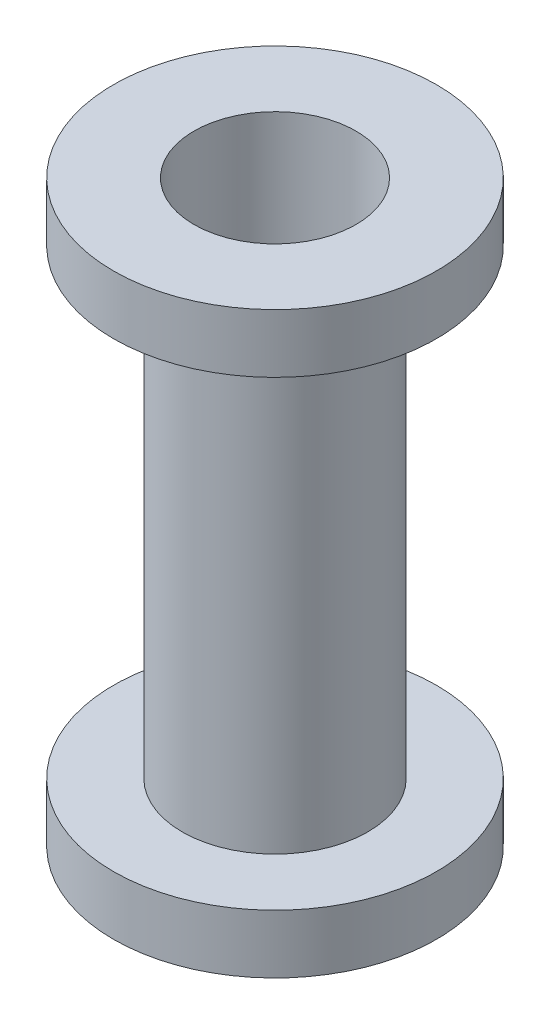
from build123d import *

# Parameters (mm, degrees)
SKETCH1_R      = 20.066
SKETCH1_R_2    = 17.526
EXTRUDE1_DEPTH = 125.222
SKETCH2_R      = 34.925
SKETCH2_R_2    = 17.526
EXTRUDE2_DEPTH = 12.7
SKETCH3_R      = 34.925
SKETCH3_R_2    = 17.526
EXTRUDE3_DEPTH = 12.7


with BuildPart() as part:
    # Sketch1 → Extrude1 (new body)
    with BuildSketch(Plane(origin=(0, 0, 0), x_dir=(1, 0, 0), z_dir=(0, 1, 0))):
        Circle(SKETCH1_R)
        Circle(SKETCH1_R_2, mode=Mode.SUBTRACT)
    extrude(amount=EXTRUDE1_DEPTH)

    # Sketch2 → Extrude2 (add)
    with BuildSketch(Plane(origin=(0, 125.222, 0), x_dir=(1, 0, 0), z_dir=(0, 1, 0))):
        Circle(SKETCH2_R)
        Circle(SKETCH2_R_2, mode=Mode.SUBTRACT)
    extrude(amount=-EXTRUDE2_DEPTH)

    # Sketch3 → Extrude3 (add)
    with BuildSketch(Plane.XZ):
        Circle(SKETCH3_R)
        Circle(SKETCH3_R_2, mode=Mode.SUBTRACT)
    extrude(amount=-EXTRUDE3_DEPTH)


solid = part.part
